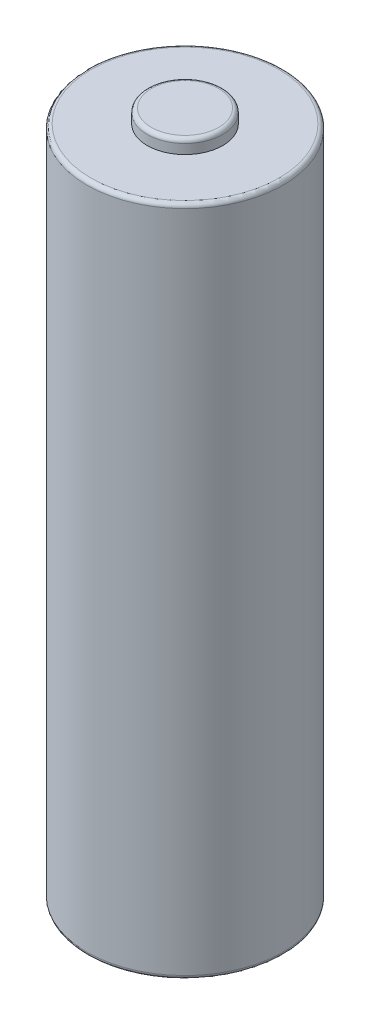
from build123d import *

# Parameters (mm, degrees)
SKETCH1_R           = 7.15
BOSS_EXTRUDE1_DEPTH = 49
SKETCH2_R           = 2.75
BOSS_EXTRUDE2_DEPTH = 1
FILLET1_R           = 0.3
SKETCH3_R           = 5
BOSS_EXTRUDE3_DEPTH = 1
FILLET3_R           = 0.1


with BuildPart() as part:
    # Sketch1 → Boss-Extrude1 (new body)
    with BuildSketch(Plane(origin=(0, 0, 0), x_dir=(1, 0, 0), z_dir=(0, 1, 0))):
        Circle(SKETCH1_R)
    extrude(amount=BOSS_EXTRUDE1_DEPTH)

    # Sketch2 → Boss-Extrude2 (add)
    with BuildSketch(Plane(origin=(0, 49, 0), x_dir=(1, 0, 0), z_dir=(0, 1, 0))):
        Circle(SKETCH2_R)
    extrude(amount=BOSS_EXTRUDE2_DEPTH)

    # Fillet1
    fillet1_edges = [part.edges().sort_by_distance(p)[0] for p in [
        (-7.15, 0, 0),
        (-7.15, 49, 0),
        (-2.75, 50, 0),
    ]]
    fillet(fillet1_edges, radius=FILLET1_R)

    # Sketch3 → Boss-Extrude3 (add)
    with BuildSketch(Plane.XZ):
        Circle(SKETCH3_R)
    extrude(amount=BOSS_EXTRUDE3_DEPTH)

    # Fillet3
    fillet3_edges = [part.edges().sort_by_distance(p)[0] for p in [
        (-5, -1, 0),
    ]]
    fillet(fillet3_edges, radius=FILLET3_R)


solid = part.part
